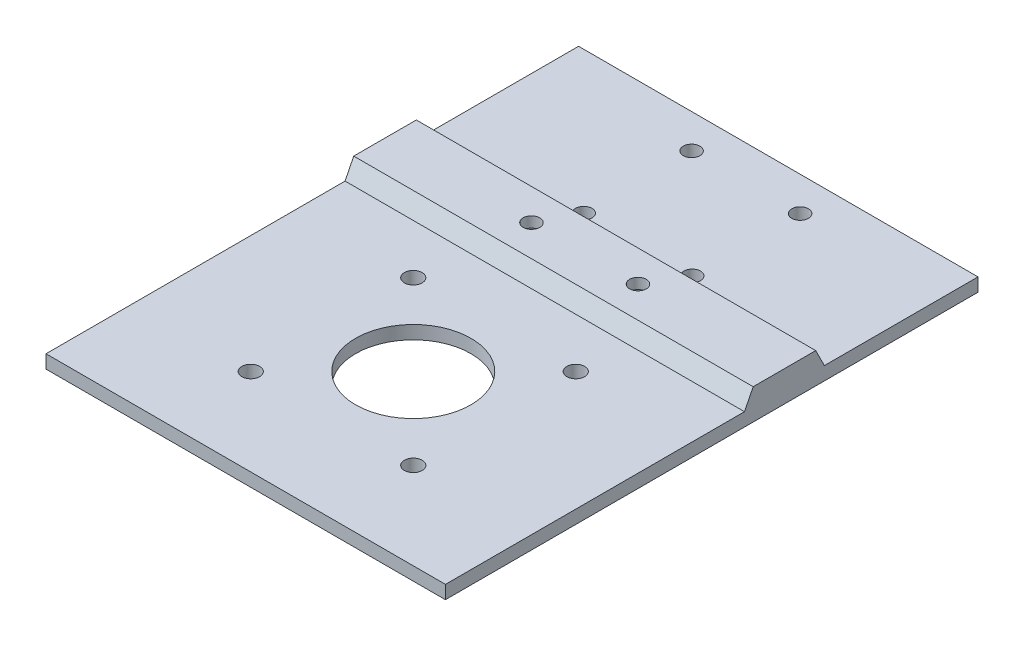
from build123d import *

# Parameters (mm, degrees)
SKETCH1_W           = 76.2
SKETCH1_H           = 101.6
BOSS_EXTRUDE1_DEPTH = 2.54
SKETCH2_R           = 1.5875
SKETCH2_R_2         = 1.70053
SKETCH2_R_3         = 10.99947
CUT_EXTRUDE1_DEPTH  = 2.54
BOSS_EXTRUDE2_DEPTH = 76.2
SKETCH4_R           = 3.175
CUT_EXTRUDE2_DEPTH  = 3.81
SKETCH5_R           = 1.5875
CUT_EXTRUDE3_DEPTH  = 3.032


with BuildPart() as part:
    # Sketch1 → Boss-Extrude1 (new body)
    with BuildSketch(Plane(origin=(0, 0, 0), x_dir=(1, 0, 0), z_dir=(0, 1, 0))):
        Rectangle(SKETCH1_W, SKETCH1_H)
    extrude(amount=BOSS_EXTRUDE1_DEPTH)

    # Sketch2 → Cut-Extrude1 (cut)
    with BuildSketch(Plane(origin=(0, 2.54, 0), x_dir=(1, 0, 0), z_dir=(0, 1, 0))):
        with Locations((-10.033800765, 44.29206639)):
            Circle(SKETCH2_R)
        with Locations((10.667199235, 44.29206639)):
            Circle(SKETCH2_R)
        with Locations((10.667199235, 23.71656639)):
            Circle(SKETCH2_R)
        with Locations((-10.033800765, 23.71656639)):
            Circle(SKETCH2_R)
        with Locations((-15.629995159, -3.207813583)):
            Circle(SKETCH2_R_2)
        with Locations((15.370704841, -3.207813583)):
            Circle(SKETCH2_R_2)
        with Locations((15.370704841, -34.208513583)):
            Circle(SKETCH2_R_2)
        with Locations((-15.629995159, -34.208513583)):
            Circle(SKETCH2_R_2)
        with Locations((-0.129645159, -18.708163583)):
            Circle(SKETCH2_R_3)
    extrude(amount=-CUT_EXTRUDE1_DEPTH, mode=Mode.SUBTRACT)

    # Sketch3 → Boss-Extrude2 (add)
    with BuildSketch(Plane(origin=(-38.1, 0, -50.8), x_dir=(0, 0, -1), z_dir=(1, 0, 0))):
        Polygon((-44.54593361, 2.54), (-29.30593361, 2.54), (-30.95693361, 5.842), (-42.89493361, 5.842), align=None)
    extrude(amount=BOSS_EXTRUDE2_DEPTH)

    # Sketch4 → Cut-Extrude2 (cut)
    with BuildSketch(Plane.XZ):
        with Locations((-10.16, -13.87406639)):
            Circle(SKETCH4_R)
        with Locations((10.16, -13.87406639)):
            Circle(SKETCH4_R)
    extrude(amount=-CUT_EXTRUDE2_DEPTH, mode=Mode.SUBTRACT)

    # Sketch5 → Cut-Extrude3 (cut, through all)
    with BuildSketch(Plane.XZ.offset(-3.81)):
        with Locations((-10.16, -13.87406639)):
            Circle(SKETCH5_R)
        with Locations((10.16, -13.87406639)):
            Circle(SKETCH5_R)
    extrude(amount=-CUT_EXTRUDE3_DEPTH, mode=Mode.SUBTRACT)


solid = part.part
